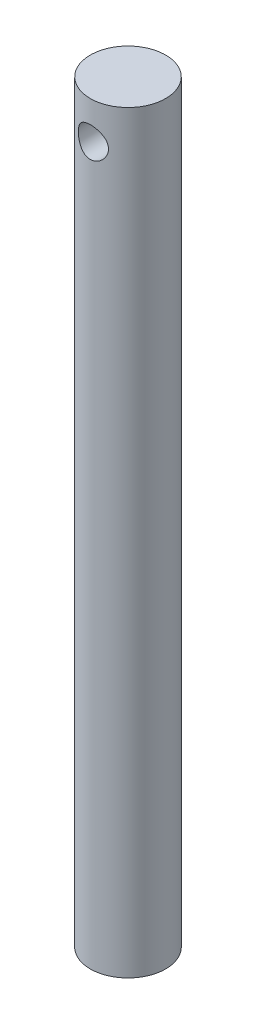
from build123d import *

# Parameters (mm, degrees)
SKETCH1_R               = 15
BOSS_EXTRUDE1_DEPTH     = 300
SKETCH2_R               = 6
CUT_EXTRUDE1_DEPTH      = 16
CUT_EXTRUDE1_DEPTH_BACK = 16
SKETCH3_R               = 4
CUT_EXTRUDE2_DEPTH      = 2.85
SKETCH4_R               = 2.25
CUT_EXTRUDE3_DEPTH      = 2.5


with BuildPart() as part:
    # Sketch1 → Boss-Extrude1 (new body)
    with BuildSketch(Plane(origin=(0, 0, 0), x_dir=(1, 0, 0), z_dir=(0, 1, 0))):
        Circle(SKETCH1_R)
    extrude(amount=BOSS_EXTRUDE1_DEPTH)

    # Sketch2 → Cut-Extrude1 (cut, two sides)
    with BuildSketch(Plane.XY) as cut_extrude1_sk:
        with Locations((0, 285)):
            Circle(SKETCH2_R)
    extrude(amount=CUT_EXTRUDE1_DEPTH, mode=Mode.SUBTRACT)
    extrude(cut_extrude1_sk.sketch, amount=-CUT_EXTRUDE1_DEPTH_BACK, mode=Mode.SUBTRACT)

    # Sketch3 → Cut-Extrude2 (cut)
    with BuildSketch(Plane.XZ):
        Circle(SKETCH3_R)
    extrude(amount=-CUT_EXTRUDE2_DEPTH, mode=Mode.SUBTRACT)

    # Sketch4 → Cut-Extrude3 (cut)
    with BuildSketch(Plane.XZ.offset(-2.85)):
        Circle(SKETCH4_R)
    extrude(amount=-CUT_EXTRUDE3_DEPTH, mode=Mode.SUBTRACT)


solid = part.part
